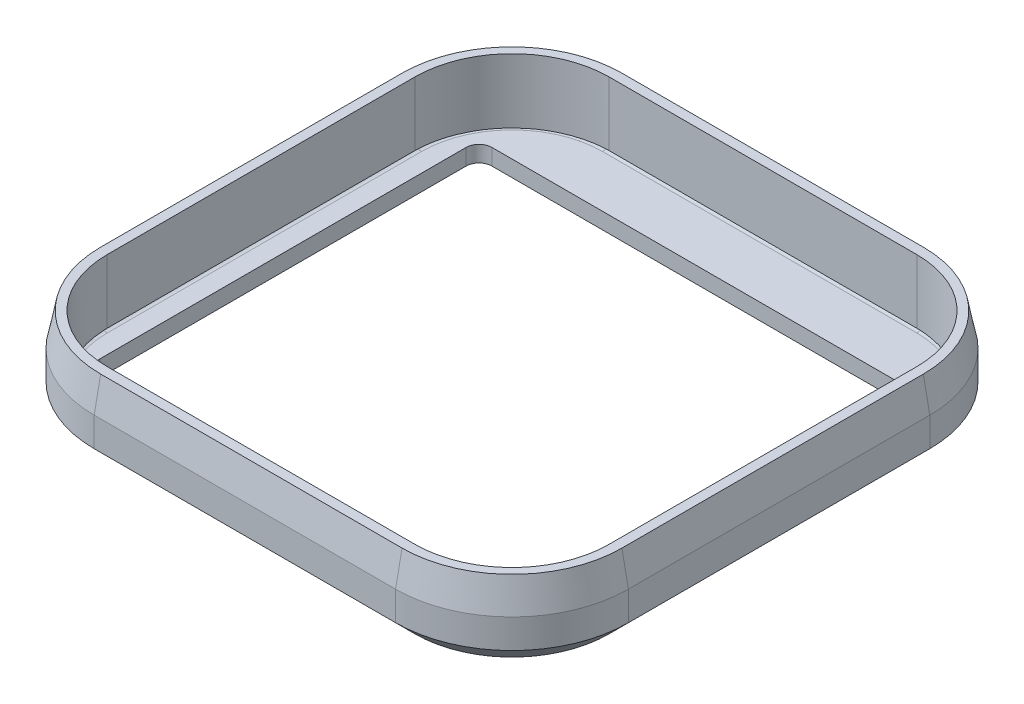
from build123d import *
from OCP.BRepFilletAPI import BRepFilletAPI_MakeChamfer

# Parameters (mm, degrees)
BOSS_EXTRUDE1_DEPTH = 12
BOSS_EXTRUDE2_DEPTH = 2
BOSS_EXTRUDE3_DEPTH = 2
FILLET1_R           = 1
CHAMFER2_SIZE       = 5
CHAMFER2_SIZE2      = 1
BOSS_EXTRUDE4_START = -2
SKETCH3_W           = 1.836045909
SKETCH3_H           = 61.241929872
SKETCH3_W_2         = 2.002550415
SKETCH3_H_2         = 60.908326167
BOSS_EXTRUDE4_DEPTH = 2
FILLET2_R           = 2
BOSS_EXTRUDE6_DEPTH = 0.5
CHAMFER3_SIZE       = 3
BOSS_EXTRUDE7_START = -9.956145
BOSS_EXTRUDE7_DEPTH = 9.956145


with BuildPart() as part:
    # Sketch1 → Boss-Extrude1 (new body)
    with BuildSketch(Plane(origin=(0, 0, 0), x_dir=(1, 0, 0), z_dir=(0, 1, 0))):
        with BuildLine():
            Line((-30.01220756, 39.409237307), (16.58779244, 39.409237307))
            ThreePointArc((16.58779244, 39.409237307), (29.315714501, 34.137159368), (34.58779244, 21.409237307))
            Line((34.58779244, 21.409237307), (34.58779244, -25.190762693))
            ThreePointArc((34.58779244, -25.190762693), (29.315714501, -37.918684754), (16.58779244, -43.190762693))
            Line((16.58779244, -43.190762693), (-30.01220756, -43.190762693))
            ThreePointArc((-30.01220756, -43.190762693), (-42.740129621, -37.918684754), (-48.01220756, -25.190762693))
            Line((-48.01220756, -25.190762693), (-48.01220756, 21.409237307))
            ThreePointArc((-48.01220756, 21.409237307), (-42.740129621, 34.137159368), (-30.01220756, 39.409237307))
        make_face()
        with BuildLine():
            ThreePointArc((-31.01220756, 37.409237307), (-41.618809278, 33.015839025), (-46.01220756, 22.409237307))
            Line((-46.01220756, 22.409237307), (-46.01220756, -26.190762693))
            ThreePointArc((-46.01220756, -26.190762693), (-41.618809278, -36.797364411), (-31.01220756, -41.190762693))
            Line((-31.01220756, -41.190762693), (17.58779244, -41.190762693))
            ThreePointArc((17.58779244, -41.190762693), (28.194394158, -36.797364411), (32.58779244, -26.190762693))
            Line((32.58779244, -26.190762693), (32.58779244, 22.409237307))
            ThreePointArc((32.58779244, 22.409237307), (28.194394158, 33.015839025), (17.58779244, 37.409237307))
            Line((17.58779244, 37.409237307), (-31.01220756, 37.409237307))
        make_face(mode=Mode.SUBTRACT)
    extrude(amount=BOSS_EXTRUDE1_DEPTH)

    # Sketch1_3 → Boss-Extrude2 (add)
    with BuildSketch(Plane(origin=(0, 0, 0), x_dir=(1, 0, 0), z_dir=(0, 1, 0))):
        with BuildLine():
            Line((-31.01220756, 37.409237307), (17.58779244, 37.409237307))
            ThreePointArc((17.58779244, 37.409237307), (28.194394158, 33.015839025), (32.58779244, 22.409237307))
            Line((32.58779244, 22.409237307), (32.58779244, -26.190762693))
            ThreePointArc((32.58779244, -26.190762693), (28.194394158, -36.797364411), (17.58779244, -41.190762693))
            Line((17.58779244, -41.190762693), (-31.01220756, -41.190762693))
            ThreePointArc((-31.01220756, -41.190762693), (-41.618809278, -36.797364411), (-46.01220756, -26.190762693))
            Line((-46.01220756, -26.190762693), (-46.01220756, 22.409237307))
            ThreePointArc((-46.01220756, 22.409237307), (-41.618809278, 33.015839025), (-31.01220756, 37.409237307))
        make_face()
        with BuildLine():
            ThreePointArc((-33.01220756, 35.409237307), (-40.790382153, 32.1874119), (-44.01220756, 24.409237307))
            Line((-44.01220756, 24.409237307), (-44.01220756, -28.190762693))
            ThreePointArc((-44.01220756, -28.190762693), (-40.790382153, -35.968937286), (-33.01220756, -39.190762693))
            Line((-33.01220756, -39.190762693), (19.58779244, -39.190762693))
            ThreePointArc((19.58779244, -39.190762693), (27.365967033, -35.968937286), (30.58779244, -28.190762693))
            Line((30.58779244, -28.190762693), (30.58779244, 24.409237307))
            ThreePointArc((30.58779244, 24.409237307), (27.365967033, 32.1874119), (19.58779244, 35.409237307))
            Line((19.58779244, 35.409237307), (-33.01220756, 35.409237307))
        make_face(mode=Mode.SUBTRACT)
    extrude(amount=BOSS_EXTRUDE2_DEPTH)

    # Sketch2 → Boss-Extrude3 (add)
    with BuildSketch(Plane.XZ):
        Polygon((-43.965284719, -28.409237307), (31.645799766, -28.409237307), (28.962058079, -33.229552195), (23.454257131, -35.92314828), (-39.267624427, -35.92314828), (-41.596405872, -34.261761517), align=None)
        Polygon((-43.464319503, 32.190762693), (31.986692978, 32.190762693), (24.084814063, 40.906543889), (12.932368974, 40.906543889), (-33.320922397, 40.906543889), (-40.968109046, 37.811254055), align=None)
    extrude(amount=-BOSS_EXTRUDE3_DEPTH)

    # Fillet1
    fillet1_edges = [part.edges().sort_by_distance(p)[0] for p in [
        (-6.71220756, 2, -37.409237307),
        (32.58779244, 2, 1.890762693),
        (28.194394158, 2, -33.015839025),
        (-41.618809278, 2, -33.015839025),
        (-46.01220756, 2, 1.890762693),
        (-41.618809278, 2, 36.797364411),
        (-6.71220756, 2, 41.190762693),
        (28.194394158, 2, 36.797364411),
    ]]
    fillet(fillet1_edges, radius=FILLET1_R)

    # Chamfer2: one chamfer whose edges measure the first distance from different faces: ONE call of the kernel's chamfer builder (chamfer() names one face for all edges)
    chamfer2_edges_1 = [part.edges().sort_by_distance(p)[0] for p in [
        (-6.71220756, 12, -39.409237307),
    ]]
    chamfer2_side_1 = [part.faces().sort_by_distance(p)[0] for p in [
        (-6.71220756, 6, -39.409237307),
    ]]
    chamfer2_edges_2 = [part.edges().sort_by_distance(p)[0] for p in [
        (-42.740129621, 12, -34.137159368),
    ]]
    chamfer2_side_2 = [part.faces().sort_by_distance(p)[0] for p in [
        (-42.740129621, 6, -34.137159368),
    ]]
    chamfer2_edges_3 = [part.edges().sort_by_distance(p)[0] for p in [
        (-48.01220756, 12, 1.890762693),
    ]]
    chamfer2_side_3 = [part.faces().sort_by_distance(p)[0] for p in [
        (-48.01220756, 6, 1.890762693),
    ]]
    chamfer2_edges_4 = [part.edges().sort_by_distance(p)[0] for p in [
        (-42.740129621, 12, 37.918684754),
    ]]
    chamfer2_side_4 = [part.faces().sort_by_distance(p)[0] for p in [
        (-42.740129621, 6, 37.918684754),
    ]]
    chamfer2_edges_5 = [part.edges().sort_by_distance(p)[0] for p in [
        (-6.71220756, 12, 43.190762693),
    ]]
    chamfer2_side_5 = [part.faces().sort_by_distance(p)[0] for p in [
        (-6.71220756, 6, 43.190762693),
    ]]
    chamfer2_edges_6 = [part.edges().sort_by_distance(p)[0] for p in [
        (29.315714501, 12, 37.918684754),
    ]]
    chamfer2_side_6 = [part.faces().sort_by_distance(p)[0] for p in [
        (29.315714501, 6, 37.918684754),
    ]]
    chamfer2_edges_7 = [part.edges().sort_by_distance(p)[0] for p in [
        (34.58779244, 12, 1.890762693),
    ]]
    chamfer2_side_7 = [part.faces().sort_by_distance(p)[0] for p in [
        (34.58779244, 6, 1.890762693),
    ]]
    chamfer2_edges_8 = [part.edges().sort_by_distance(p)[0] for p in [
        (29.315714501, 12, -34.137159368),
    ]]
    chamfer2_side_8 = [part.faces().sort_by_distance(p)[0] for p in [
        (29.315714501, 6, -34.137159368),
    ]]
    chamfer2 = BRepFilletAPI_MakeChamfer(part.part.solid().wrapped)
    for e in chamfer2_edges_1:
        chamfer2.Add(CHAMFER2_SIZE, CHAMFER2_SIZE2, e.wrapped, chamfer2_side_1[0].wrapped)  # the first distance lies on this face
    for e in chamfer2_edges_2:
        chamfer2.Add(CHAMFER2_SIZE, CHAMFER2_SIZE2, e.wrapped, chamfer2_side_2[0].wrapped)  # the first distance lies on this face
    for e in chamfer2_edges_3:
        chamfer2.Add(CHAMFER2_SIZE, CHAMFER2_SIZE2, e.wrapped, chamfer2_side_3[0].wrapped)  # the first distance lies on this face
    for e in chamfer2_edges_4:
        chamfer2.Add(CHAMFER2_SIZE, CHAMFER2_SIZE2, e.wrapped, chamfer2_side_4[0].wrapped)  # the first distance lies on this face
    for e in chamfer2_edges_5:
        chamfer2.Add(CHAMFER2_SIZE, CHAMFER2_SIZE2, e.wrapped, chamfer2_side_5[0].wrapped)  # the first distance lies on this face
    for e in chamfer2_edges_6:
        chamfer2.Add(CHAMFER2_SIZE, CHAMFER2_SIZE2, e.wrapped, chamfer2_side_6[0].wrapped)  # the first distance lies on this face
    for e in chamfer2_edges_7:
        chamfer2.Add(CHAMFER2_SIZE, CHAMFER2_SIZE2, e.wrapped, chamfer2_side_7[0].wrapped)  # the first distance lies on this face
    for e in chamfer2_edges_8:
        chamfer2.Add(CHAMFER2_SIZE, CHAMFER2_SIZE2, e.wrapped, chamfer2_side_8[0].wrapped)  # the first distance lies on this face
    add(Compound.cast(chamfer2.Shape()), mode=Mode.REPLACE)

    # Sketch3 → Boss-Extrude4 (add)
    with BuildSketch(Plane.XZ.offset(BOSS_EXTRUDE4_START)):
        with Locations((29.686081831, 1.878123924)):
            Rectangle(SKETCH3_W, SKETCH3_H)
        with Locations((-43.113419178, 2.044925776)):
            Rectangle(SKETCH3_W_2, SKETCH3_H_2)
    extrude(amount=BOSS_EXTRUDE4_DEPTH)

    # Fillet2
    fillet2_edges = [part.edges().sort_by_distance(p)[0] for p in [
        (28.768058876, 1, 32.190762693),
        (28.768058876, 1, -28.409237307),
        (-42.11214397, 1, 32.190762693),
        (-42.11214397, 1, -28.409237307),
    ]]
    fillet(fillet2_edges, radius=FILLET2_R)

    # Sketch4 → Boss-Extrude6 (add)
    with BuildSketch(Plane.XZ):
        with BuildLine():
            Line((-30.01220756, -39.409237307), (16.58779244, -39.409237307))
            ThreePointArc((16.58779244, -39.409237307), (29.315714501, -34.137159368), (34.58779244, -21.409237307))
            Line((34.58779244, -21.409237307), (34.58779244, 25.190762693))
            ThreePointArc((34.58779244, 25.190762693), (29.315714501, 37.918684754), (16.58779244, 43.190762693))
            Line((16.58779244, 43.190762693), (-30.01220756, 43.190762693))
            ThreePointArc((-30.01220756, 43.190762693), (-42.740129621, 37.918684754), (-48.01220756, 25.190762693))
            Line((-48.01220756, 25.190762693), (-48.01220756, -21.409237307))
            ThreePointArc((-48.01220756, -21.409237307), (-42.740129621, -34.137159368), (-30.01220756, -39.409237307))
        make_face()
        with BuildLine():
            Line((-40.11214397, -28.409237307), (26.768058876, -28.409237307))
            ThreePointArc((26.768058876, -28.409237307), (28.182272439, -27.823450869), (28.768058876, -26.409237307))
            Line((28.768058876, -26.409237307), (28.768058876, 30.190762693))
            ThreePointArc((28.768058876, 30.190762693), (28.182272439, 31.604976255), (26.768058876, 32.190762693))
            Line((26.768058876, 32.190762693), (-40.11214397, 32.190762693))
            ThreePointArc((-40.11214397, 32.190762693), (-41.526357532, 31.604976255), (-42.11214397, 30.190762693))
            Line((-42.11214397, 30.190762693), (-42.11214397, -26.409237307))
            ThreePointArc((-42.11214397, -26.409237307), (-41.526357532, -27.823450869), (-40.11214397, -28.409237307))
        make_face(mode=Mode.SUBTRACT)
    extrude(amount=BOSS_EXTRUDE6_DEPTH)

    # Chamfer3
    chamfer3_edges = [part.edges().sort_by_distance(p)[0] for p in [
        (-42.740129621, -0.5, -34.137159368),
        (-6.71220756, -0.5, -39.409237307),
        (29.315714501, -0.5, -34.137159368),
        (34.58779244, -0.5, 1.890762693),
        (29.315714501, -0.5, 37.918684754),
        (-6.71220756, -0.5, 43.190762693),
        (-42.740129621, -0.5, 37.918684754),
        (-48.01220756, -0.5, 1.890762693),
    ]]
    chamfer(chamfer3_edges, length=CHAMFER3_SIZE)

    # Sketch5 → Boss-Extrude7 (add)
    with BuildSketch(Plane(origin=(0, 12, 0), x_dir=(1, 0, 0), z_dir=(0, 1, 0)).offset(BOSS_EXTRUDE7_START)):
        with BuildLine():
            Line((17.58779244, 37.409237307), (-31.01220756, 37.409237307))
            ThreePointArc((-31.01220756, 37.409237307), (-41.618809278, 33.015839025), (-46.01220756, 22.409237307))
            Line((-46.01220756, 22.409237307), (-46.01220756, -26.190762693))
            ThreePointArc((-46.01220756, -26.190762693), (-41.618809278, -36.797364411), (-31.01220756, -41.190762693))
            Line((-31.01220756, -41.190762693), (17.58779244, -41.190762693))
            ThreePointArc((17.58779244, -41.190762693), (28.194394158, -36.797364411), (32.58779244, -26.190762693))
            Line((32.58779244, -26.190762693), (32.58779244, 22.409237307))
            ThreePointArc((32.58779244, 22.409237307), (28.194394158, 33.015839025), (17.58779244, 37.409237307))
        make_face()
        with BuildLine():
            Line((-30.51220756, 36.909237307), (17.08779244, 36.909237307))
            ThreePointArc((17.08779244, 36.909237307), (27.694394158, 32.515839025), (32.08779244, 21.909237307))
            Line((32.08779244, 21.909237307), (32.08779244, -25.690762693))
            ThreePointArc((32.08779244, -25.690762693), (27.694394158, -36.297364411), (17.08779244, -40.690762693))
            Line((17.08779244, -40.690762693), (-30.51220756, -40.690762693))
            ThreePointArc((-30.51220756, -40.690762693), (-41.118809278, -36.297364411), (-45.51220756, -25.690762693))
            Line((-45.51220756, -25.690762693), (-45.51220756, 21.909237307))
            ThreePointArc((-45.51220756, 21.909237307), (-41.118809278, 32.515839025), (-30.51220756, 36.909237307))
        make_face(mode=Mode.SUBTRACT)
    extrude(amount=BOSS_EXTRUDE7_DEPTH)


solid = part.part
